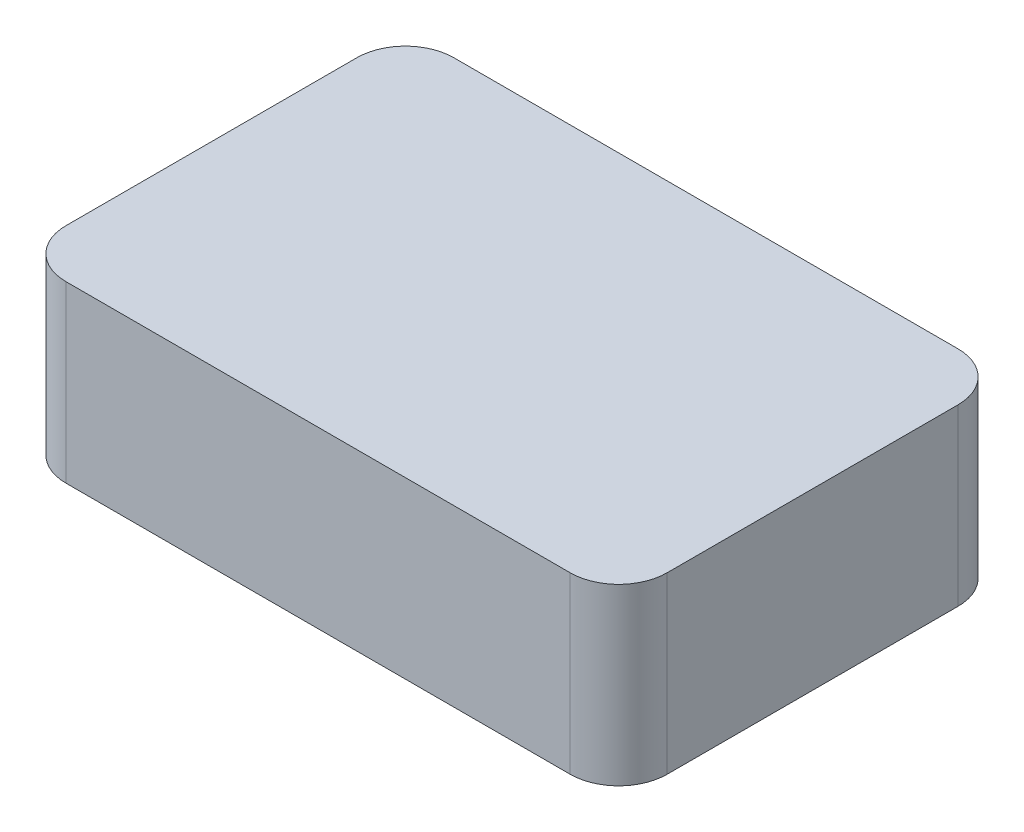
from build123d import *

# Parameters (mm, degrees)
SKETCH1_W           = 31
SKETCH1_H           = 20
BOSS_EXTRUDE1_DEPTH = 4.5
FILLET1_R           = 2.5


with BuildPart() as part:
    # Sketch1 → Boss-Extrude1 (new body, symmetric)
    with BuildSketch(Plane(origin=(0, 0, 0), x_dir=(1, 0, 0), z_dir=(0, 1, 0))):
        Rectangle(SKETCH1_W, SKETCH1_H)
    extrude(amount=BOSS_EXTRUDE1_DEPTH, both=True)

    # Fillet1
    fillet1_edges = [part.edges().sort_by_distance(p)[0] for p in [
        (15.5, 0, 10),
        (-15.5, 0, 10),
        (-15.5, 0, -10),
        (15.5, 0, -10),
    ]]
    fillet(fillet1_edges, radius=FILLET1_R)


solid = part.part
